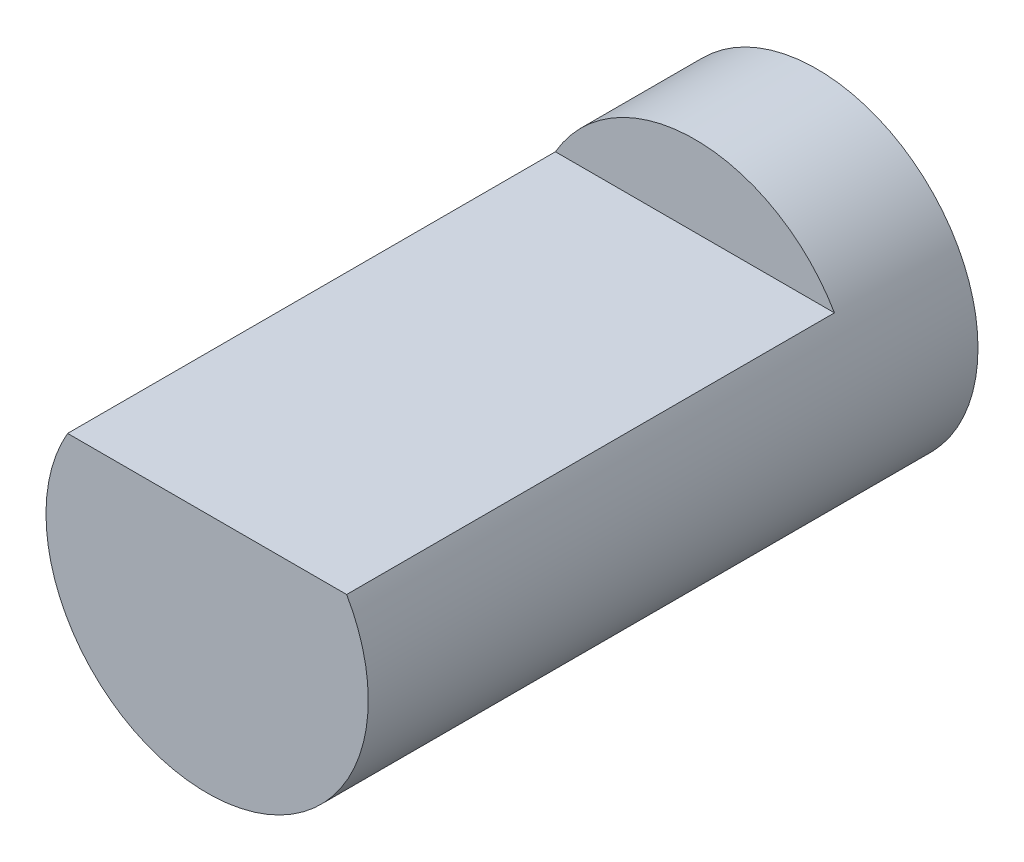
from build123d import *

# Parameters (mm, degrees)
SKETCH1_R           = 5.285260403
BOSS_EXTRUDE1_DEPTH = 20
CUT_EXTRUDE8_DEPTH  = 16


with BuildPart() as part:
    # Sketch1 → Boss-Extrude1 (new body)
    with BuildSketch(Plane.XY):
        Circle(SKETCH1_R)
    extrude(amount=BOSS_EXTRUDE1_DEPTH)

    # Sketch4 → Cut-Extrude8 (cut)
    with BuildSketch(Plane.XY.offset(20)):
        with BuildLine():
            Line((-4.576345902, 2.644056678), (4.576345902, 2.644056678))
            ThreePointArc((4.576345902, 2.644056678), (0, 5.285260403), (-4.576345902, 2.644056678))
        make_face()
    extrude(amount=-CUT_EXTRUDE8_DEPTH, mode=Mode.SUBTRACT)


solid = part.part
